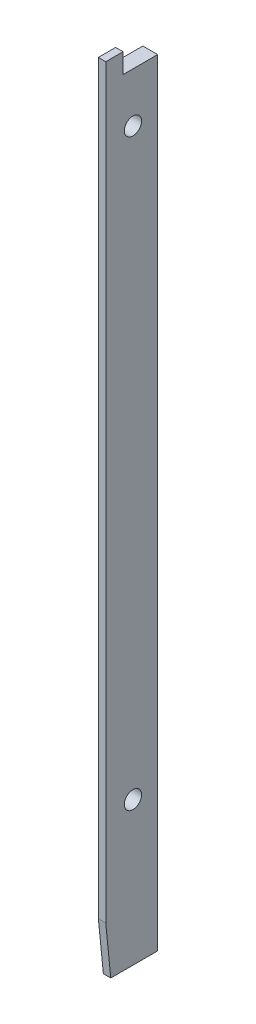
from build123d import *

# Parameters (mm, degrees)
SKETCH1_W           = 3
SKETCH1_H           = 7
BOSS_EXTRUDE1_DEPTH = 157
SKETCH2_W           = 1.5
SKETCH2_H           = 161
BOSS_EXTRUDE2_DEPTH = 3.5
SKETCH3_R           = 1.75
CUT_EXTRUDE1_DEPTH  = 4
CUT_EXTRUDE2_DEPTH  = 4


with BuildPart() as part:
    # Sketch1 → Boss-Extrude1 (new body)
    with BuildSketch(Plane(origin=(0, 0, 0), x_dir=(1, 0, 0), z_dir=(0, 1, 0))):
        with Locations((1.5, 3.5)):
            Rectangle(SKETCH1_W, SKETCH1_H)
    extrude(amount=BOSS_EXTRUDE1_DEPTH)

    # Sketch2 → Boss-Extrude2 (add)
    with BuildSketch(Plane.XY):
        with Locations((2.25, 80.5)):
            Rectangle(SKETCH2_W, SKETCH2_H)
    extrude(amount=BOSS_EXTRUDE2_DEPTH)

    # Sketch3 → Cut-Extrude1 (cut, through all)
    with BuildSketch(Plane(origin=(3, 0, 0), x_dir=(0, 0, -1), z_dir=(1, 0, 0))):
        with Locations((2, 147)):
            Circle(SKETCH3_R)
        with Locations((2, 29)):
            Circle(SKETCH3_R)
    extrude(amount=-CUT_EXTRUDE1_DEPTH, mode=Mode.SUBTRACT)

    # Sketch4 → Cut-Extrude2 (cut, through all)
    with BuildSketch(Plane(origin=(3, 0, 0), x_dir=(0, 0, -1), z_dir=(1, 0, 0))):
        Polygon((-2.485167134, 0), (-3.5, 10.149389846), (-3.5, 0), align=None)
    extrude(amount=-CUT_EXTRUDE2_DEPTH, mode=Mode.SUBTRACT)


solid = part.part
